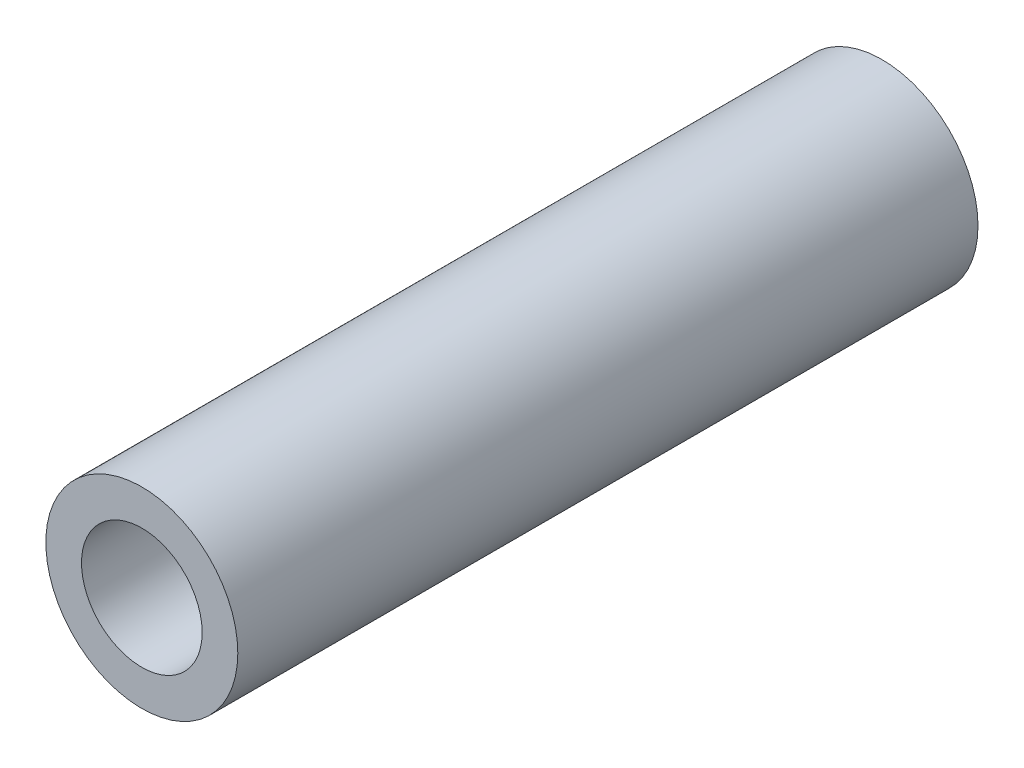
from build123d import *

# Parameters (mm, degrees)
SKETCH_1_W      = 26.990014613
SKETCH_1_H      = 7
M10X1_251_D     = 8.8
M10X1_251_DEPTH = 26.25
M10X1_251_TIP   = 2.643786724


with BuildPart() as part:
    # Эскиз1 → Повернуть1 (revolve)
    with BuildSketch(Plane(origin=(0, 0, 0), x_dir=(0, 0, -1), z_dir=(1, 0, 0))):
        with Locations((-13.495007307, 3.5)):
            Rectangle(SKETCH_1_W, SKETCH_1_H)
    revolve(axis=Axis((0, 0, 1000), (0, 0, -1)))

    # Отверстие обработанное метчиком M10x1.251
    with Locations(Plane.XY.offset(26.990014613)):
        with Locations((0, 0)):
            Hole(M10X1_251_D / 2, depth=M10X1_251_DEPTH)
            with Locations((0, 0, -(M10X1_251_DEPTH + M10X1_251_TIP / 2))):  # 118° drill point
                Cone(0, M10X1_251_D / 2, M10X1_251_TIP, mode=Mode.SUBTRACT)

    # Зеркальное отражение1: part across plane


with BuildPart() as part_1:
    add(part.part)
    add(part.part.mirror(Plane.XY))


solid = part_1.part
